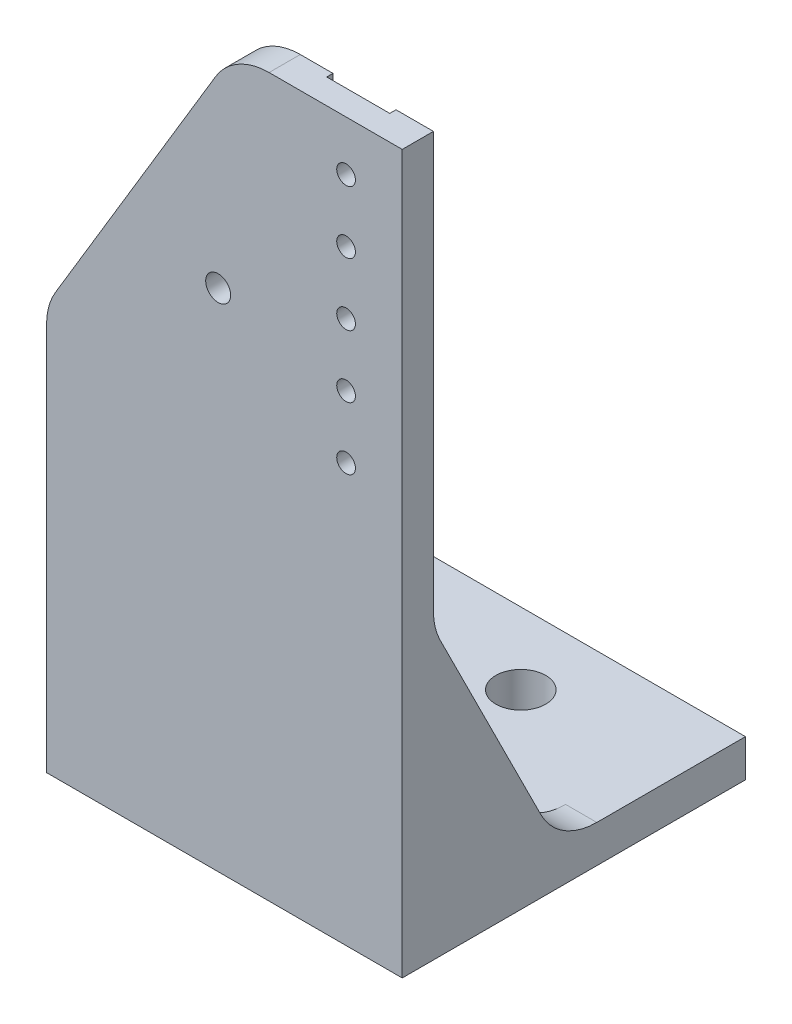
from build123d import *

# Parameters (mm, degrees)
SKETCH_1_W                 = 40
SKETCH_1_H                 = 10
SKETCH_1_H_2               = 15
EXTRUDE_1_DEPTH            = 6
SKETCH_3_R                 = 3
SKETCH_3_R_2               = 4
CUT_EXTRUDE_1_DEPTH        = 7
CUT_EXTRUDE_2_DEPTH        = 1
SKETCH_6_R                 = 2
EXTRUDE_2_DEPTH            = 5
SKETCH_7_R                 = 1.5
CUT_EXTRUDE_4_DEPTH        = 6
SKETCH_8_W                 = 10.1
SKETCH_8_H                 = 55
SKETCH_8_R                 = 1.5
CUT_EXTRUDE_5_DEPTH        = 1
SKETCH_9_R                 = 6
CUT_EXTRUDE_6_DEPTH        = 2
SKETCH_10_W                = 65
SKETCH_10_H                = 15
EXTRUDE_3_DEPTH            = 6
SKETCH_11_R                = 4
CUT_EXTRUDE_7_DEPTH        = 6
SKETCH_12_W                = 161.966486937
SKETCH_12_H                = 199.843871975
CUT_EXTRUDE_8_DEPTH        = 8
PATTERN_LINEAR_1_COUNT     = 3
PATTERN_LINEAR_1_PITCH     = 10
PATTERN_LINEAR_1_COL_COUNT = 3
PATTERN_LINEAR_1_COL_PITCH = 10
CHAMFER_1_SIZE             = 30
CHAMFER_1_SIZE2            = 50
FILLET_1_R                 = 10
EXTRUDE_4_DEPTH            = 5
FILLET_2_R                 = 10


with BuildPart() as part:
    # 草图1 → 凸台-拉伸1 (new body)
    with BuildSketch(Plane(origin=(0, 0, 0), x_dir=(1, 0, 0), z_dir=(0, 1, 0))):
        with Locations((20, -5)):
            Rectangle(SKETCH_1_W, SKETCH_1_H)
        with Locations((20, 7.5)):
            Rectangle(SKETCH_1_W, SKETCH_1_H_2)
        with Locations((20, -15)):
            Rectangle(SKETCH_1_W, SKETCH_1_H)
        Polygon((-20, 15), (-20, -20), (0, -20), (0, -10), (0, 0), (0, 15), align=None)
        Polygon((45, -20), (40, -20), (40, -10), (40, 0), (40, 15), (45, 15), align=None)
    extrude(amount=EXTRUDE_1_DEPTH)

    # 草图3 → 切除-拉伸1 (cut, through all)
    with BuildSketch(Plane(origin=(0, 6, 0), x_dir=(1, 0, 0), z_dir=(0, 1, 0))):
        with Locations((12.5, -6.5)):
            Circle(SKETCH_3_R)
        with Locations((-12.5, -6.5)):
            Circle(SKETCH_3_R_2)
    extrude(amount=-CUT_EXTRUDE_1_DEPTH, mode=Mode.SUBTRACT)

    # 草图4 → 切除-拉伸2 (cut)
    with BuildSketch(Plane(origin=(0, 6, 0), x_dir=(1, 0, 0), z_dir=(0, 1, 0))):
        with BuildLine():
            Line((6.5, -6.5), (9.5, -6.5))
            ThreePointArc((9.5, -6.5), (12.5, -3.5), (15.5, -6.5))
            ThreePointArc((15.5, -6.5), (14.621320344, -8.621320344), (12.5, -9.5))
            Line((12.5, -9.5), (12.5, -19))
            Line((12.5, -19), (21.5, -19))
            Line((21.5, -19), (21.5, 7))
            Line((21.5, 7), (6.5, 7))
            Line((6.5, 7), (6.5, -6.5))
        make_face()
        with BuildLine():
            ThreePointArc((12.5, -9.5), (10.378679656, -8.621320344), (9.5, -6.5))
            Line((9.5, -6.5), (6.5, -6.5))
            Line((6.5, -6.5), (6.5, -19))
            Line((6.5, -19), (12.5, -19))
            Line((12.5, -19), (12.5, -9.5))
        make_face()
    extrude(amount=-CUT_EXTRUDE_2_DEPTH, mode=Mode.SUBTRACT)

    # 草图6 → 凸台-拉伸2 (add)
    with BuildSketch(Plane.XY.offset(20)):
        Polygon((-20, 0), (12.5, 0), (45, 0), (45, 115), (-20, 115), align=None)
        with Locations((7.5, 81)):
            Circle(SKETCH_6_R, mode=Mode.SUBTRACT)
    extrude(amount=EXTRUDE_2_DEPTH)

    # 草图7 → 切除-拉伸4 (cut, through all)
    with BuildSketch(Plane(origin=(0, 0, 20), x_dir=(-1, 0, 0), z_dir=(0, 0, -1))):
        with Locations((-28, 87)):
            Circle(SKETCH_7_R)
    cut_extrude_4 = extrude(amount=-CUT_EXTRUDE_4_DEPTH, mode=Mode.SUBTRACT)

    # 草图8 → 切除-拉伸5 (cut)
    with BuildSketch(Plane(origin=(0, 0, 20), x_dir=(-1, 0, 0), z_dir=(0, 0, -1))):
        with Locations((-25.95, 87.5)):
            Rectangle(SKETCH_8_W, SKETCH_8_H)
        with Locations((-28, 87)):
            Circle(SKETCH_8_R, mode=Mode.SUBTRACT)
    extrude(amount=-CUT_EXTRUDE_5_DEPTH, mode=Mode.SUBTRACT)

    # 草图9 → 切除-拉伸6 (cut)
    with BuildSketch(Plane.XZ):
        with Locations((12.5, 6.5)):
            Circle(SKETCH_9_R)
    extrude(amount=-CUT_EXTRUDE_6_DEPTH, mode=Mode.SUBTRACT)

    # 草图10 → 凸台-拉伸3 (add)
    with BuildSketch(Plane.XZ):
        with Locations((12.5, -22.5)):
            Rectangle(SKETCH_10_W, SKETCH_10_H)
    extrude(amount=-EXTRUDE_3_DEPTH)

    # 草图11 → 切除-拉伸7 (cut)
    with BuildSketch(Plane(origin=(0, 6, 0), x_dir=(1, 0, 0), z_dir=(0, 1, 0))):
        with Locations((12.5, 18.5)):
            Circle(SKETCH_11_R)
    extrude(amount=-CUT_EXTRUDE_7_DEPTH, mode=Mode.SUBTRACT)

    # 草图12 → 切除-拉伸8 (cut)
    with BuildSketch(Plane(origin=(45, 0, 0), x_dir=(0, 0, -1), z_dir=(1, 0, 0))):
        with Locations((-40.373481837, 95.367627035)):
            Rectangle(SKETCH_12_W, SKETCH_12_H)
    extrude(amount=-CUT_EXTRUDE_8_DEPTH, mode=Mode.SUBTRACT)

    # 阵列(线性)1: 切除-拉伸4 ×3
    with Locations(*[(0, -i * PATTERN_LINEAR_1_PITCH, 0) for i in range(1, PATTERN_LINEAR_1_COUNT)]):
        add(cut_extrude_4, mode=Mode.SUBTRACT)

    # 阵列(线性)1 col: 切除-拉伸4 ×3
    with Locations(*[(0, i * PATTERN_LINEAR_1_COL_PITCH, 0) for i in range(1, PATTERN_LINEAR_1_COL_COUNT)]):
        add(cut_extrude_4, mode=Mode.SUBTRACT)

    # 倒角1
    chamfer_1_edges = [part.edges().sort_by_distance(p)[0] for p in [
        (-20, 115, 22.5),
    ]]
    chamfer_1_side = [part.faces().sort_by_distance(p)[0] for p in [
        (7.858875955, 115, 22.573481266),
    ]]
    chamfer(chamfer_1_edges, length=CHAMFER_1_SIZE, length2=CHAMFER_1_SIZE2, reference=chamfer_1_side[0])

    # 圆角1
    fillet_1_edges = [part.edges().sort_by_distance(p)[0] for p in [
        (-20, 65, 22.5),
        (10, 115, 22.5),
    ]]
    fillet(fillet_1_edges, radius=FILLET_1_R)

    # 草图13 → 凸台-拉伸4 (add)
    with BuildSketch(Plane(origin=(37, 0, 0), x_dir=(0, 0, -1), z_dir=(1, 0, 0))):
        Polygon((-20, 6), (0, 6), (-20, 46), align=None)
    extrude(amount=-EXTRUDE_4_DEPTH)

    # 圆角2
    fillet_2_edges = [part.edges().sort_by_distance(p)[0] for p in [
        (34.5, 46, 20),
        (34.5, 6, 0),
    ]]
    fillet(fillet_2_edges, radius=FILLET_2_R)


solid = part.part
